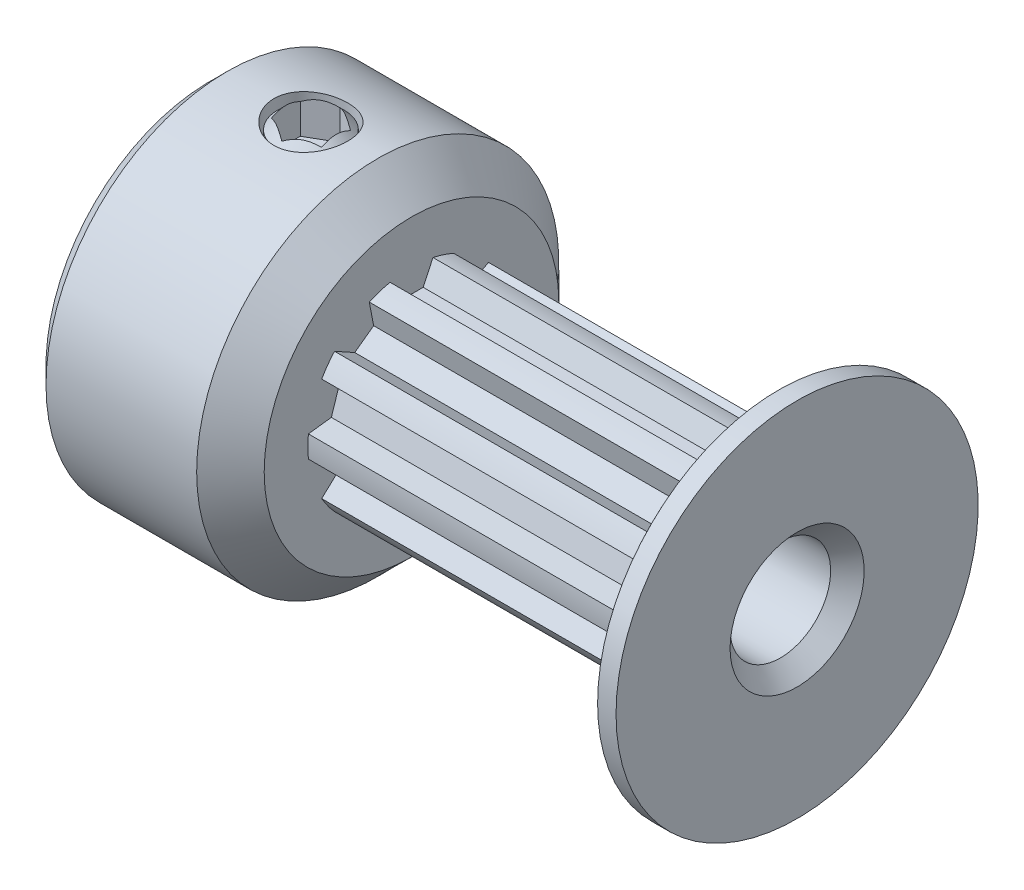
from build123d import *

# Parameters (mm, degrees)
SKETCH4_R          = 3.25
SKETCH4_R_2        = 3.09125
CUT_EXTRUDE2_DEPTH = 10.4
CUT_EXTRUDE1_DEPTH = 10.4
CIRPATTERN1_COUNT  = 10
SKETCH6_R          = 1.1
CUT_EXTRUDE3_DEPTH = 12.613892543
CUT_EXTRUDE4_DEPTH = 1.016
CHAMFER1_SIZE      = 0.5


with BuildPart() as part:
    # Sketch1 → Revolve1 (revolve)
    with BuildSketch(Plane.XY, mode=Mode.PRIVATE) as revolve1_sk:
        with BuildLine():
            Line((-8.75, 1.5), (8.75, 1.5))
            Line((8.75, 1.5), (8.75, 5.4))
            Line((8.75, 5.4), (8.2, 5.4))
            ThreePointArc((8.2, 5.4), (7.791437689, 4.657287391), (7.65, 3.8215))
            Line((7.65, 3.8215), (7.65, 3.25))
            Line((7.65, 3.25), (-2.75, 3.25))
            Line((-2.75, 3.25), (-2.75, 4.393))
            Line((-2.75, 4.393), (-3.757, 5.4))
            Line((-3.757, 5.4), (-8.75, 5.4))
            Line((-8.75, 5.4), (-8.75, 1.5))
        make_face()
    revolve(revolve1_sk.sketch.rotate(Axis((-8.75, 0, 0), (1, 0, 0)), 90), axis=Axis((-8.75, 0, 0), (1, 0, 0)))

    # Sketch4 → Cut-Extrude2 (cut)
    with BuildSketch(Plane(origin=(-2.75, 0, 0), x_dir=(0, 0, -1), z_dir=(1, 0, 0))):
        Circle(SKETCH4_R)
        with Locations(Location((0, 0, 0), (0, 0, 180))):
            Circle(SKETCH4_R_2, mode=Mode.SUBTRACT)
    extrude(amount=CUT_EXTRUDE2_DEPTH, mode=Mode.SUBTRACT)

    # Sketch3 → Cut-Extrude1 (cut)
    with BuildSketch(Plane(origin=(-2.75, 0, 0), x_dir=(0, 0, -1), z_dir=(1, 0, 0))):
        with BuildLine():
            Line((-0.640467525, 3.024173922), (-0.349056738, 2.399241473))
            Line((-0.349056738, 2.399241473), (0.349056738, 2.399241473))
            Line((0.349056738, 2.399241473), (0.640467525, 3.024173922))
            ThreePointArc((0.640467525, 3.024173922), (0, 3.09125), (-0.640467525, 3.024173922))
        make_face()
    cut_extrude1 = extrude(amount=CUT_EXTRUDE1_DEPTH, mode=Mode.SUBTRACT)

    # CirPattern1: Cut-Extrude1 ×10 about axis
    cirpattern1_axis = Axis((0, 0, 0), (1, 0, 0))
    for i in range(1, CIRPATTERN1_COUNT):
        add(cut_extrude1.rotate(cirpattern1_axis, i * 360 / CIRPATTERN1_COUNT), mode=Mode.SUBTRACT)

    # Sketch6 → Cut-Extrude3 (cut, through all)
    with BuildSketch(Plane(origin=(0, 0, 0), x_dir=(1, 0, 0), z_dir=(0, 1, 0))):
        with Locations(Location((-5.75, 0, 0), (0, 0, 90))):
            Circle(SKETCH6_R)
    extrude(amount=CUT_EXTRUDE3_DEPTH, mode=Mode.SUBTRACT)

    # Chamfer1
    chamfer1_edges = [part.edges().sort_by_distance(p)[0] for p in [
        (-8.75, 0, -5.4),
        (-8.75, 0, -1.5),
        (8.75, 0, -1.5),
    ]]
    chamfer(chamfer1_edges, length=CHAMFER1_SIZE)


with BuildPart() as body_2:
    # Sketch7 → Revolve2 (revolve)
    with BuildSketch(Plane.XY, mode=Mode.PRIVATE) as revolve2_sk:
        Polygon((-6.496, 5.4), (-5.75, 5.4), (-5.75, 1.881), (-6.496, 1.881), (-6.75, 2.135), (-6.75, 5.146), align=None)
    revolve(revolve2_sk.sketch.rotate(Axis((-5.75, 1.881, 0), (0, 1, 0)), 270), axis=Axis((-5.75, 1.881, 0), (0, 1, 0)))

    # Sketch8 → Cut-Extrude4 (cut)
    with BuildSketch(Plane(origin=(0, 5.4, 0), x_dir=(1, 0, 0), z_dir=(0, 1, 0))):
        Polygon((-5.75, 0.866025404), (-6.5, 0.433012702), (-6.5, -0.433012702), (-5.75, -0.866025404), (-5, -0.433012702), (-5, 0.433012702), align=None)
    extrude(amount=-CUT_EXTRUDE4_DEPTH, mode=Mode.SUBTRACT)


solid = Compound([part.part, body_2.part])
